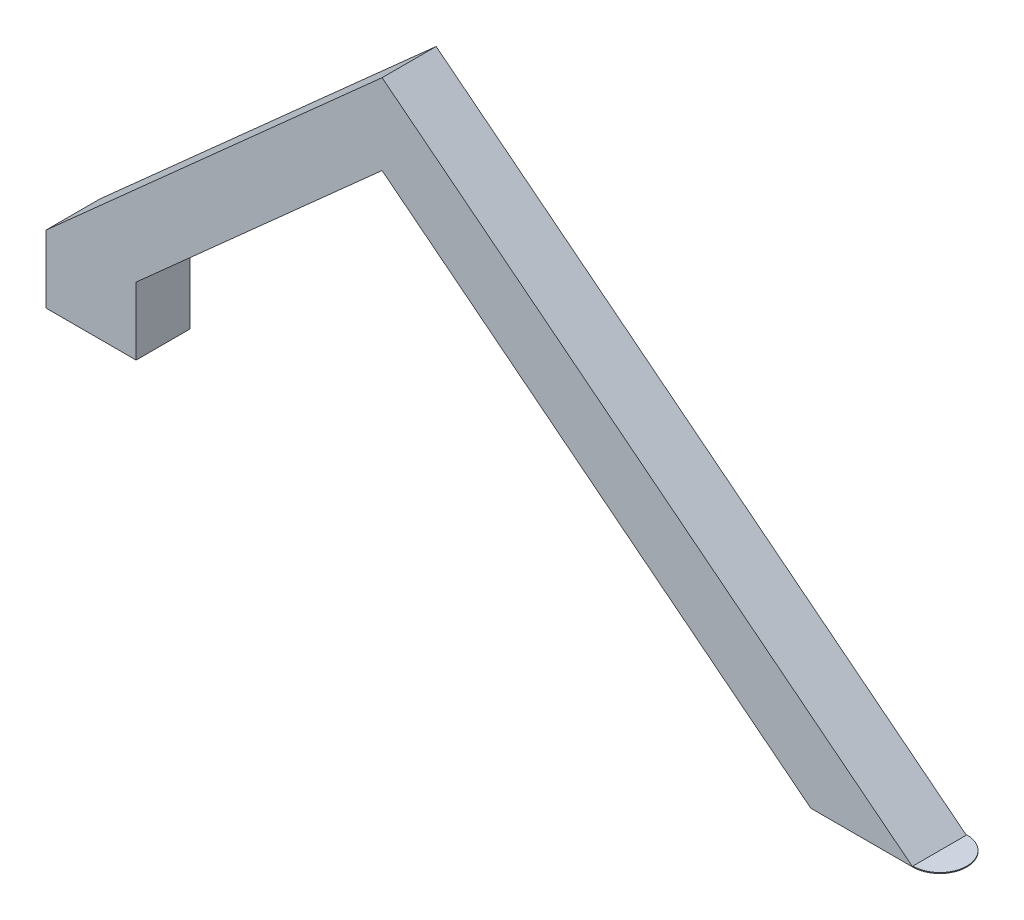
from build123d import *

# Parameters (mm, degrees)
BOSS_EXTRUDE1_DEPTH = 12
BOSS_EXTRUDE2_DEPTH = 0.2
SKETCH4_R           = 1
CUT_EXTRUDE1_DEPTH  = 1


with BuildPart() as part:
    # Sketch1 → Boss-Extrude1 (new body)
    with BuildSketch(Plane.XY):
        Polygon((-10, 0), (-10, 15), (64.600301578, 81.594256543), (182.405421436, -11.260219575), (159.754414724, -11.260219575), (64.600301578, 63.740640637), (10, 15), (10, 0), align=None)
    extrude(amount=BOSS_EXTRUDE1_DEPTH)

    # Sketch4 → Cut-Extrude1 (cut)
    with BuildSketch(Plane.XZ):
        with Locations((0, 6)):
            Circle(SKETCH4_R)
    extrude(amount=-CUT_EXTRUDE1_DEPTH, mode=Mode.SUBTRACT)


with BuildPart() as body_2:
    # Sketch3 → Boss-Extrude2 (new body)
    with BuildSketch(Plane.XZ.offset(11.260219575)):
        with BuildLine():
            Line((182.405421436, 12), (182.405421436, 0))
            ThreePointArc((182.405421436, 0), (188.405421436, 6), (182.405421436, 12))
        make_face()
    extrude(amount=-BOSS_EXTRUDE2_DEPTH)


solid = Compound([part.part, body_2.part])
